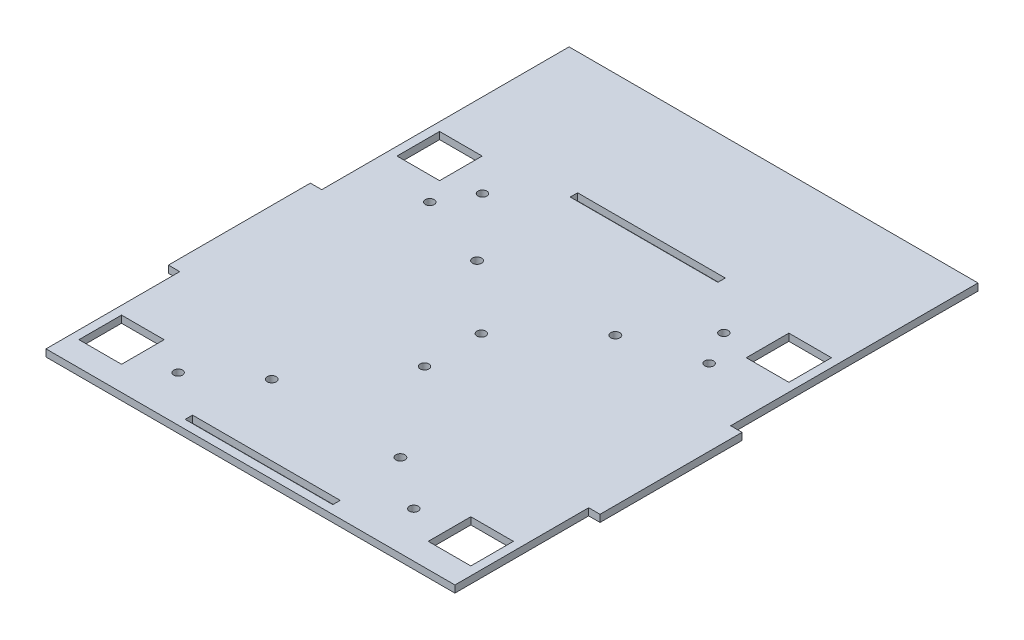
from build123d import *

# Parameters (mm, degrees)
SKETCH1_R           = 1.55
SKETCH1_R_2         = 1.6
SKETCH1_W           = 15
SKETCH1_H           = 15
SKETCH1_W_2         = 52
SKETCH1_H_2         = 2.6
BOSS_EXTRUDE1_DEPTH = 2.5
SKETCH2_W           = 144
SKETCH2_H           = 40
BOSS_EXTRUDE2_DEPTH = 2.5


with BuildPart() as part:
    # Sketch1 → Boss-Extrude1 (new body)
    with BuildSketch(Plane(origin=(0, 0, 0), x_dir=(1, 0, 0), z_dir=(0, 1, 0))):
        Polygon((-72, -25), (-76, -25), (-76, 25), (-72, 25), (-72, 72.1), (72, 72.1), (72, 25), (76, 25), (76, -25), (72, -25), (72, -72.1), (-72, -72.1), align=None)
        with Locations((0, -10.804905882)):
            Circle(SKETCH1_R, mode=Mode.SUBTRACT)
        with Locations((0, 9.195094118)):
            Circle(SKETCH1_R, mode=Mode.SUBTRACT)
        with Locations((-49.186770493, 40.239784928)):
            Circle(SKETCH1_R, mode=Mode.SUBTRACT)
        with Locations((49.186770493, 40.239784928)):
            Circle(SKETCH1_R, mode=Mode.SUBTRACT)
        with Locations((-41.500164476, -56.081111214)):
            Circle(SKETCH1_R, mode=Mode.SUBTRACT)
        with Locations((41.500164476, -56.081111214)):
            Circle(SKETCH1_R, mode=Mode.SUBTRACT)
        with Locations((-23, 30.701748775)):
            Circle(SKETCH1_R_2, mode=Mode.SUBTRACT)
        with Locations((24.1, 32.301748775)):
            Circle(SKETCH1_R_2, mode=Mode.SUBTRACT)
        with Locations((23.5, -42.798251225)):
            Circle(SKETCH1_R_2, mode=Mode.SUBTRACT)
        with Locations((-23, -41.598251225)):
            Circle(SKETCH1_R_2, mode=Mode.SUBTRACT)
        with Locations((42.5, 52.1)):
            Circle(SKETCH1_R, mode=Mode.SUBTRACT)
        with Locations((-42.5, 52.1)):
            Circle(SKETCH1_R, mode=Mode.SUBTRACT)
        with Locations((61.5, 56)):
            Rectangle(SKETCH1_W, SKETCH1_H, mode=Mode.SUBTRACT)
        with Locations((-61.5, 56)):
            Rectangle(SKETCH1_W, SKETCH1_H, mode=Mode.SUBTRACT)
        with Locations((0, -67.8)):
            Rectangle(SKETCH1_W_2, SKETCH1_H_2, mode=Mode.SUBTRACT)
        with Locations((0, 67.8)):
            Rectangle(SKETCH1_W_2, SKETCH1_H_2, mode=Mode.SUBTRACT)
        with Locations((-61.5, -56)):
            Rectangle(SKETCH1_W, SKETCH1_H, mode=Mode.SUBTRACT)
        with Locations((61.5, -56)):
            Rectangle(SKETCH1_W, SKETCH1_H, mode=Mode.SUBTRACT)
    extrude(amount=BOSS_EXTRUDE1_DEPTH)

    # Sketch2 → Boss-Extrude2 (add)
    with BuildSketch(Plane(origin=(0, 2.5, 0), x_dir=(1, 0, 0), z_dir=(0, 1, 0))):
        with Locations((0, 92.1)):
            Rectangle(SKETCH2_W, SKETCH2_H)
    extrude(amount=-BOSS_EXTRUDE2_DEPTH)


solid = part.part
